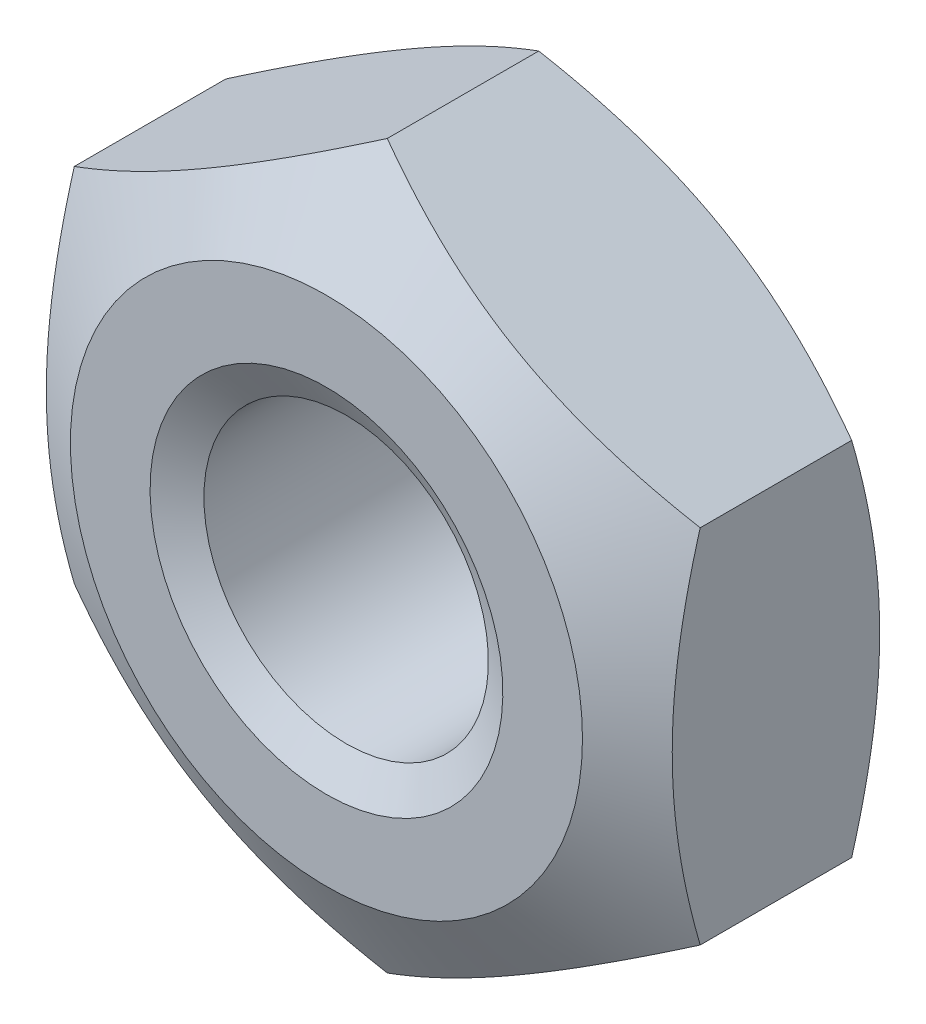
from build123d import *

# Parameters (mm, degrees)
BOSS_EXTRUDE1_DEPTH = 2.4


with BuildPart() as part:
    # Sketch1 → Boss-Extrude1 (new body)
    with BuildSketch(Plane.XY):
        Polygon((0, 3.175426481), (-2.75, 1.58771324), (-2.75, -1.58771324), (0, -3.175426481), (2.75, -1.58771324), (2.75, 1.58771324), align=None)
    extrude(amount=-BOSS_EXTRUDE1_DEPTH)

    # Sketch4 → Cut-Revolve1 (revolve, cut)
    with BuildSketch(Plane(origin=(0, 0, 0), x_dir=(0, 0, -1), z_dir=(1, 0, 0))):
        Polygon((2.4, 3.175426481), (1.865704772, 3.175426481), (2.4, 2.25), align=None)
        Polygon((0, 3.175426481), (0.534295228, 3.175426481), (0, 2.25), align=None)
    revolve(axis=Axis((0, 0, 0), (0, 0, -1)), mode=Mode.SUBTRACT)

    # Sketch5 → Cut-Revolve2 (revolve, cut)
    with BuildSketch(Plane(origin=(0, 0, 0), x_dir=(0, 0, -1), z_dir=(1, 0, 0))):
        Polygon((0, 0), (0, 1.55), (0.173205081, 1.25), (2.226794919, 1.25), (2.4, 1.55), (2.4, 0), align=None)
    revolve(axis=Axis((0, 0, 0), (0, 0, -1)), mode=Mode.SUBTRACT)


solid = part.part
